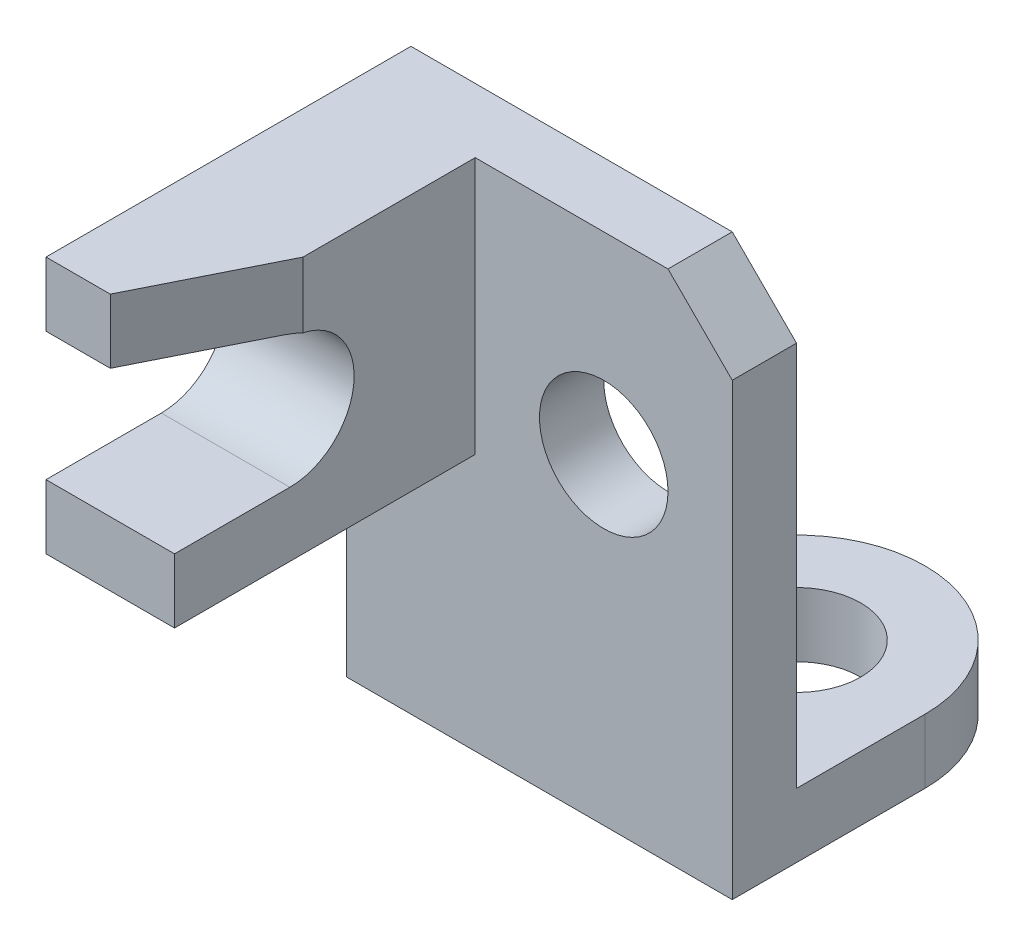
from build123d import *

# Parameters (mm, degrees)
SKETCH1_R           = 1
BOSS_EXTRUDE1_DEPTH = 1
SKETCH2_R           = 1
BOSS_EXTRUDE2_DEPTH = 1
BOSS_EXTRUDE3_DEPTH = 2
CUT_EXTRUDE1_DEPTH  = 2


with BuildPart() as part:
    # Sketch1 → Boss-Extrude1 (new body)
    with BuildSketch(Plane.XY):
        Polygon((5, 8), (6, 7), (6, 0), (0, 0), (0, 8), align=None)
        with Locations((4, 5)):
            Circle(SKETCH1_R, mode=Mode.SUBTRACT)
    extrude(amount=-BOSS_EXTRUDE1_DEPTH)

    # Sketch2 → Boss-Extrude2 (add)
    with BuildSketch(Plane.XZ):
        with BuildLine():
            Line((6, -1), (6, -2.999291988))
            ThreePointArc((6, -2.999291988), (4, -4.999291988), (2, -2.999291988))
            Line((2, -2.999291988), (2, -1))
            Line((2, -1), (6, -1))
        make_face()
        with Locations((4, -2.999291988)):
            Circle(SKETCH2_R, mode=Mode.SUBTRACT)
    extrude(amount=-BOSS_EXTRUDE2_DEPTH)

    # Sketch3 → Boss-Extrude3 (add)
    with BuildSketch(Plane.ZY):
        with BuildLine():
            Line((0, 8), (0, 4))
            Line((0, 4), (4.678841552, 4))
            Line((4.678841552, 4), (4.678841552, 5))
            Line((4.678841552, 5), (2.884219665, 5))
            ThreePointArc((2.884219665, 5), (1.884219665, 6), (2.884219665, 7))
            Line((2.884219665, 7), (4.678841552, 7))
            Line((4.678841552, 7), (4.678841552, 8))
            Line((4.678841552, 8), (0, 8))
        make_face()
    extrude(amount=-BOSS_EXTRUDE3_DEPTH)

    # Sketch4 → Cut-Extrude1 (cut)
    with BuildSketch(Plane(origin=(0, 8, 0), x_dir=(1, 0, 0), z_dir=(0, 1, 0))):
        Polygon((1, -4.678841552), (2, -2.678841552), (2, -4.678841552), align=None)
    extrude(amount=-CUT_EXTRUDE1_DEPTH, mode=Mode.SUBTRACT)


solid = part.part
